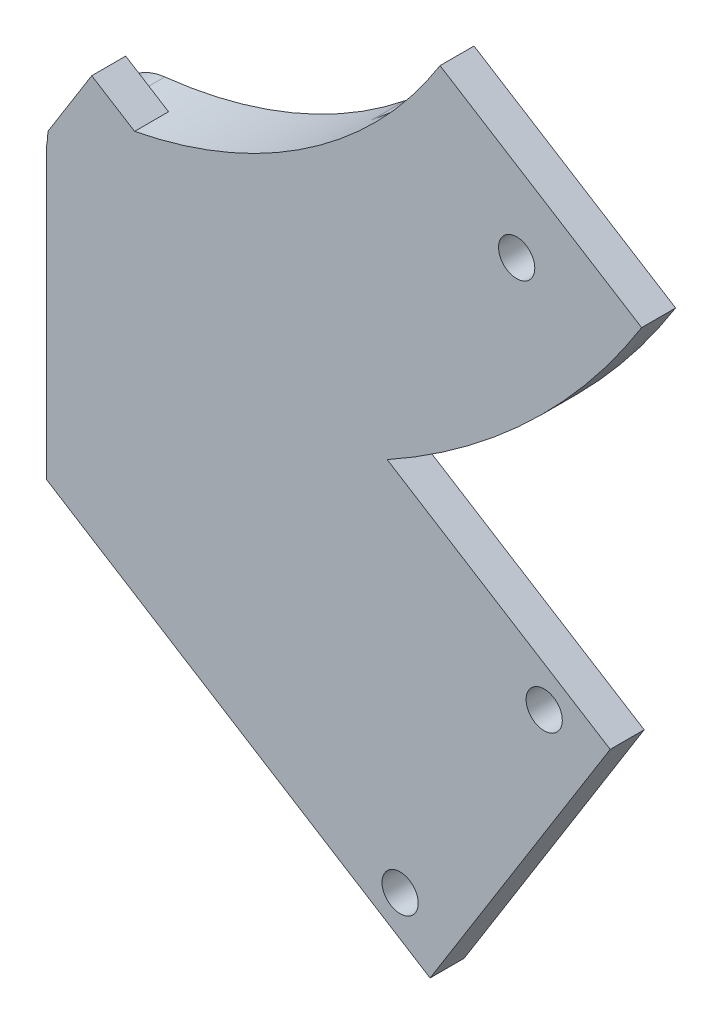
from build123d import *

# Parameters (mm, degrees)
EXTRUDE_1_DEPTH = 3
FILLET_1_R      = 5
SKETCH_2_R      = 1.6000000000000019
EXTRUDE_2_DEPTH = 3
FILLET_2_R      = 5
SKETCH_3_R      = 1.6000000000000008
SKETCH_3_R_2    = 1.6000000000000012
EXTRUDE_3_DEPTH = 3


with BuildPart() as part:
    # 草图1 → 凸台-拉伸1 (new body)
    with BuildSketch(Plane.XY):
        with BuildLine():
            Line((-20.304339314515776, -30.013405439405844), (-20.304339314515772, -51.013405439405844))
            ThreePointArc((-20.304339314515772, -51.013405439405844), (3.4220334921198514, -46.293936455105595), (23.536281119050262, -32.854025872971704))
            Line((23.536281119050262, -32.854025872971704), (8.687038714132733, -18.00478346805423))
            ThreePointArc((8.687038714132733, -18.00478346805423), (-4.614318587547064, -26.892466272368587), (-20.304339314515776, -30.013405439405844))
        make_face()
    extrude(amount=EXTRUDE_1_DEPTH)

    # 圆角1
    fillet_1_edges = [part.edges().sort_by_distance(p)[0] for p in [
        (8.687038714132733, -18.004783468054235, 1.5),
        (23.53628111905026, -32.854025872971704, 1.5),
        (-20.304339314515772, -51.013405439405844, 1.5),
        (-20.304339314515772, -30.013405439405844, 1.5),
    ]]
    fillet(fillet_1_edges, radius=FILLET_1_R)

    # 草图2 → 凸台-拉伸2 (add)
    with BuildSketch(Plane.XY.offset(3)):
        with BuildLine():
            Line((-20.30433931451578, -30.013405439405844), (-20.30433931451578, -51.013405439405865))
            ThreePointArc((-20.30433931451578, -51.013405439405865), (9.745319415064024, -43.24455894212779), (32.26429472639552, -21.884954156689382))
            Line((32.26429472639552, -21.884954156689382), (14.45878964802233, -10.751042494383663))
            ThreePointArc((14.45878964802233, -10.751042494383663), (-0.43279079979365775, -24.87594243314131), (-20.30433931451578, -30.013405439405844))
        make_face()
        with Locations((21.227676100740037, -22.06013948042292)):
            Circle(SKETCH_2_R, mode=Mode.SUBTRACT)
    extrude(amount=EXTRUDE_2_DEPTH)

    # 圆角2
    fillet_2_edges = [part.edges().sort_by_distance(p)[0] for p in [
        (-20.30433931451578, -30.013405439405844, 4.5),
        (-20.30433931451578, -51.01340543940586, 4.5),
    ]]
    fillet(fillet_2_edges, radius=FILLET_2_R)

    # 草图3 → 凸台-拉伸3 (add)
    with BuildSketch(Plane.XY.offset(6)):
        Polygon((-16.298731474091507, -26.90045671258201), (29.48685301315381, -55.53051527279668), (13.581264924145668, -80.96695109904408), (-20.30433931451578, -59.778036628128184), (-20.30433931451578, -34.74085890010055), (-20.159852559425826, -33.075214801052134), align=None)
        with Locations((-13.649884311951084, -32.09503164337476)):
            Circle(SKETCH_3_R, mode=Mode.SUBTRACT)
        with Locations((23.656888233211756, -55.42322750725339)):
            Circle(SKETCH_3_R, mode=Mode.SUBTRACT)
        with Locations((10.932417762005228, -75.7723761682513)):
            Circle(SKETCH_3_R_2, mode=Mode.SUBTRACT)
    extrude(amount=-EXTRUDE_3_DEPTH)


solid = part.part
